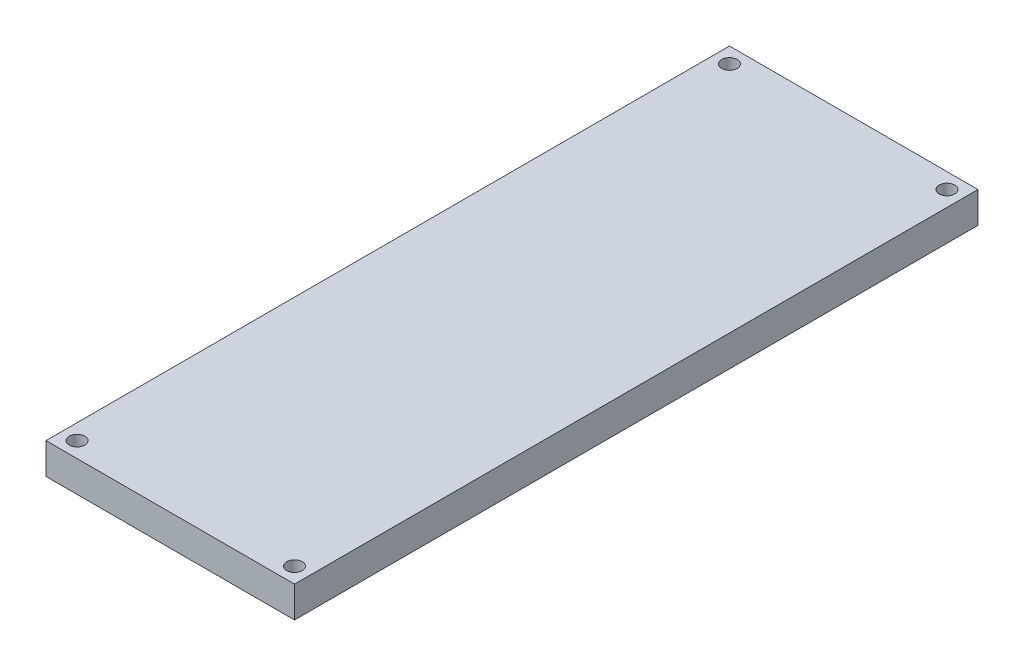
from build123d import *

# Parameters (mm, degrees)
SKETCH1_W                                     = 101.6
SKETCH1_H                                     = 279.4
BASE_SHAPE_DEPTH                              = 12.7
SKETCH2_R                                     = 3.175
F_0_25_DIAMETER_CLEARANCE_HOLES_FOR_LID_DEPTH = 12.7


with BuildPart() as part:
    # Sketch1 → Base Shape (new body)
    with BuildSketch(Plane(origin=(0, 0, 0), x_dir=(1, 0, 0), z_dir=(0, 1, 0))):
        Rectangle(SKETCH1_W, SKETCH1_H)
    extrude(amount=BASE_SHAPE_DEPTH)

    # Sketch2 → 0.25_ Diameter Clearance Holes for Lid (cut)
    with BuildSketch(Plane(origin=(0, 12.7, 0), x_dir=(1, 0, 0), z_dir=(0, 1, 0))):
        with Locations((-44.45, -133.35)):
            Circle(SKETCH2_R)
        with Locations((44.45, -133.35)):
            Circle(SKETCH2_R)
        with Locations((44.45, 133.35)):
            Circle(SKETCH2_R)
        with Locations((-44.45, 133.35)):
            Circle(SKETCH2_R)
    extrude(amount=-F_0_25_DIAMETER_CLEARANCE_HOLES_FOR_LID_DEPTH, mode=Mode.SUBTRACT)


solid = part.part
